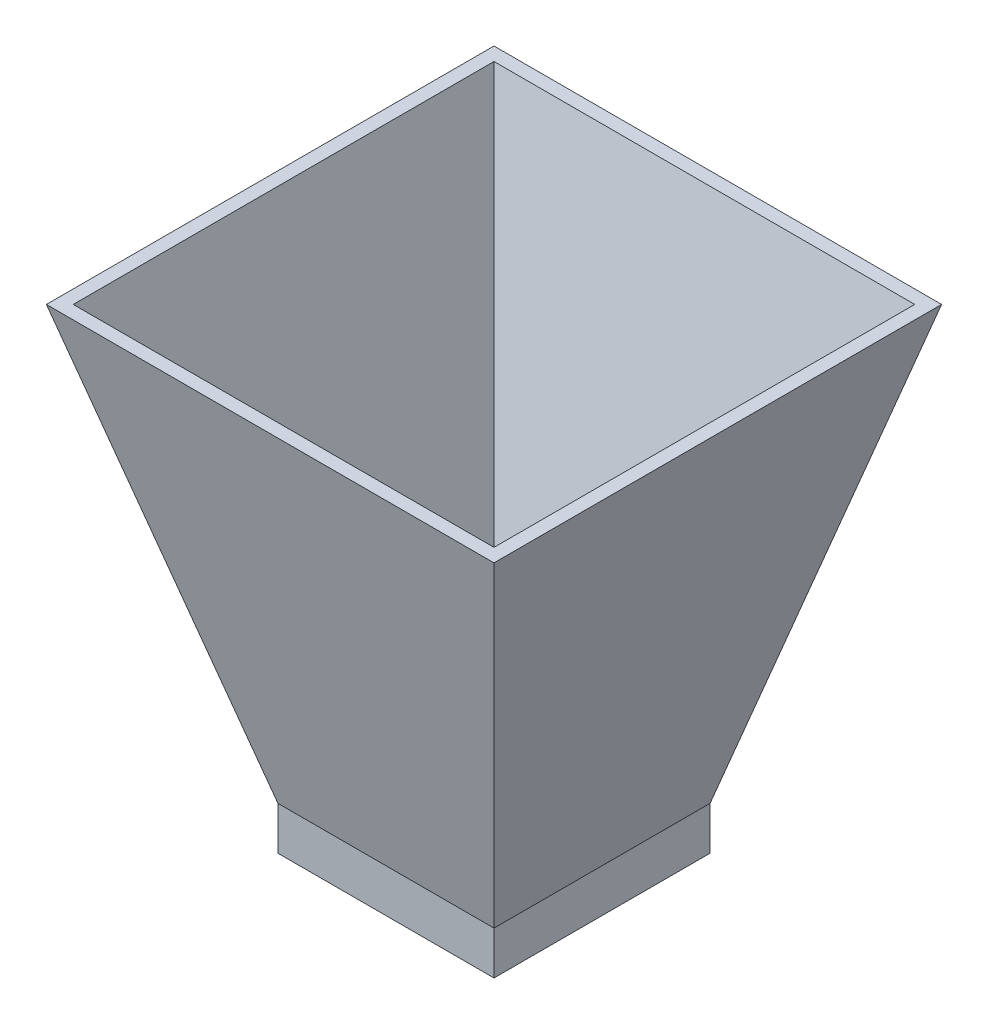
from build123d import *

# Parameters (mm, degrees)
SKETCH1_W           = 50
SKETCH1_H           = 50
BOSS_EXTRUDE1_DEPTH = 100
BOSS_EXTRUDE1_TAPER = -15
SHELL1_T            = -3
SKETCH2_W           = 44
SKETCH2_H           = 44
CUT_EXTRUDE1_DEPTH  = 101.000000137
SKETCH3_W           = 50
SKETCH3_H           = 50
SKETCH3_W_2         = 44
SKETCH3_H_2         = 44
BOSS_EXTRUDE2_DEPTH = 10


with BuildPart() as part:
    # Sketch1 → Boss-Extrude1 (new body)
    with BuildSketch(Plane(origin=(0, 0, 0), x_dir=(1, 0, 0), z_dir=(0, 1, 0))):
        with Locations((25, -25)):
            Rectangle(SKETCH1_W, SKETCH1_H)
    extrude(amount=BOSS_EXTRUDE1_DEPTH, taper=BOSS_EXTRUDE1_TAPER)

    # Shell1
    shell1_openings = [part.faces().sort_by_distance(p)[0] for p in [
        (25, 100, 25),
    ]]
    offset(amount=SHELL1_T, openings=shell1_openings, kind=Kind.INTERSECTION)

    # Sketch2 → Cut-Extrude1 (cut, through all)
    with BuildSketch(Plane.XZ):
        with Locations((25, 25)):
            Rectangle(SKETCH2_W, SKETCH2_H)
    extrude(amount=-CUT_EXTRUDE1_DEPTH, mode=Mode.SUBTRACT)

    # Sketch3 → Boss-Extrude2 (add)
    with BuildSketch(Plane.XZ):
        with Locations((25, 25)):
            Rectangle(SKETCH3_W, SKETCH3_H)
        with Locations((25, 25)):
            Rectangle(SKETCH3_W_2, SKETCH3_H_2, mode=Mode.SUBTRACT)
    extrude(amount=BOSS_EXTRUDE2_DEPTH)


solid = part.part
